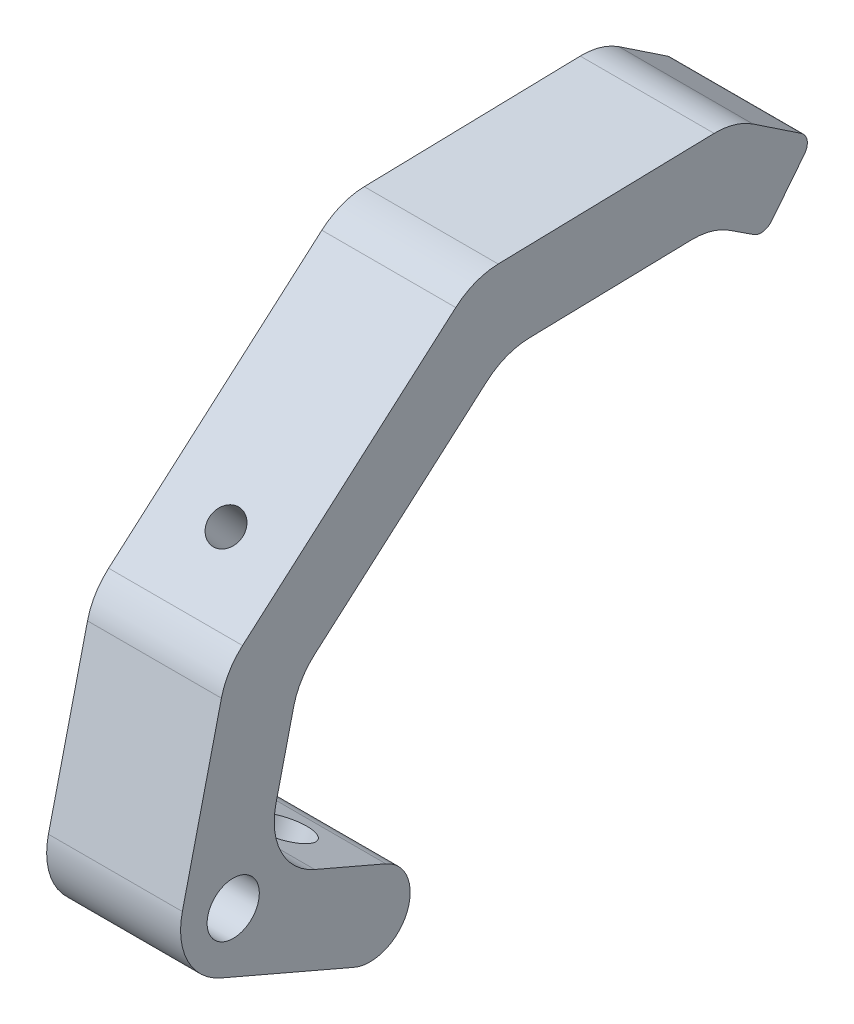
from build123d import *

# Parameters (mm, degrees)
SKETCH1_R           = 4.953
BOSS_EXTRUDE1_DEPTH = 25.4
FILLET1_R           = 12.7
FILLET2_R           = 2.54
CUT_EXTRUDE3_REACH  = 130.474
SKETCH5_R           = 5.08
CUT_EXTRUDE4_REACH  = 120.723
SKETCH7_R           = 3.175


with BuildPart() as part:
    # Sketch1 → Boss-Extrude1 (new body)
    with BuildSketch(Plane(origin=(0, 0, 0), x_dir=(0, 0, -1), z_dir=(1, 0, 0))):
        with BuildLine():
            Line((103.901886641, 61.637766497), (113.279686218, 73.483555297))
            Line((113.279686218, 73.483555297), (98.451355982, 83.391276702))
            Line((98.451355982, 83.391276702), (48.882530567, 82.21455605))
            Line((48.882530567, 82.21455605), (1.911791408, 41.210560809))
            Line((1.911791408, 41.210560809), (-8.886551045, -4.469459574))
            Line((-8.886551045, -4.469459574), (26.146598357, -19.557154557))
            ThreePointArc((26.146598357, -19.557154557), (36.159220082, -15.57265883), (32.174724356, -5.560037105))
            Line((32.174724356, -5.560037105), (8.886551045, 4.469459574))
            Line((8.886551045, 4.469459574), (15.618065001, 32.945653592))
            Line((15.618065001, 32.945653592), (54.753455571, 67.109633069))
            Line((54.753455571, 67.109633069), (94.084630156, 68.043320825))
            Line((94.084630156, 68.043320825), (103.901886641, 61.637766497))
        make_face()
        with Locations((3.213640173, 1.616289015)):
            Circle(SKETCH1_R, mode=Mode.SUBTRACT)
    extrude(amount=BOSS_EXTRUDE1_DEPTH)

    # Fillet1
    fillet1_edges = [part.edges().sort_by_distance(p)[0] for p in [
        (12.7, 68.043320825, -94.084630156),
        (12.7, 67.109633069, -54.753455571),
        (12.7, 32.945653592, -15.618065001),
        (12.7, 4.469459574, -8.886551045),
        (12.7, -4.469459574, 8.886551045),
        (12.7, 41.210560809, -1.911791408),
        (12.7, 82.21455605, -48.882530567),
        (12.7, 83.391276702, -98.451355982),
    ]]
    fillet(fillet1_edges, radius=FILLET1_R)

    # Fillet2
    fillet2_edges = [part.edges().sort_by_distance(p)[0] for p in [
        (12.7, 73.483555297, -113.279686218),
        (12.7, 61.637766497, -103.901886641),
    ]]
    fillet(fillet2_edges, radius=FILLET2_R)

    # Sketch5 → Cut-Extrude3 (cut, up to next)
    with BuildSketch(Plane(origin=(0, -6.998558726, 3.014062999), x_dir=(1, 0, 0), z_dir=(0, -0.918446027, 0.395546325)), mode=Mode.PRIVATE) as cut_extrude3_sk1:
        with Locations((12.7, -24.13)):
            Circle(SKETCH5_R)
    cut_extrude3_tool1 = extrude(cut_extrude3_sk1.sketch, amount=-CUT_EXTRUDE3_REACH, mode=Mode.PRIVATE) & part.part
    add(cut_extrude3_tool1.solids().sort_by_distance((12.7, -16.543092, -19.14804))[0], mode=Mode.SUBTRACT)

    # Sketch7 → Cut-Extrude4 (cut, up to next)
    with BuildSketch(Plane(origin=(0, 22.440379915, 19.589754126), x_dir=(1, 0, 0), z_dir=(0, 0.753334468, 0.657637574)), mode=Mode.PRIVATE) as cut_extrude4_sk1:
        with Locations((12.7, 45.316910599)):
            Circle(SKETCH7_R)
    cut_extrude4_tool1 = extrude(cut_extrude4_sk1.sketch, amount=-CUT_EXTRUDE4_REACH, mode=Mode.PRIVATE) & part.part
    add(cut_extrude4_tool1.solids().sort_by_distance((12.7, 52.242483, -14.549037))[0], mode=Mode.SUBTRACT)


solid = part.part
